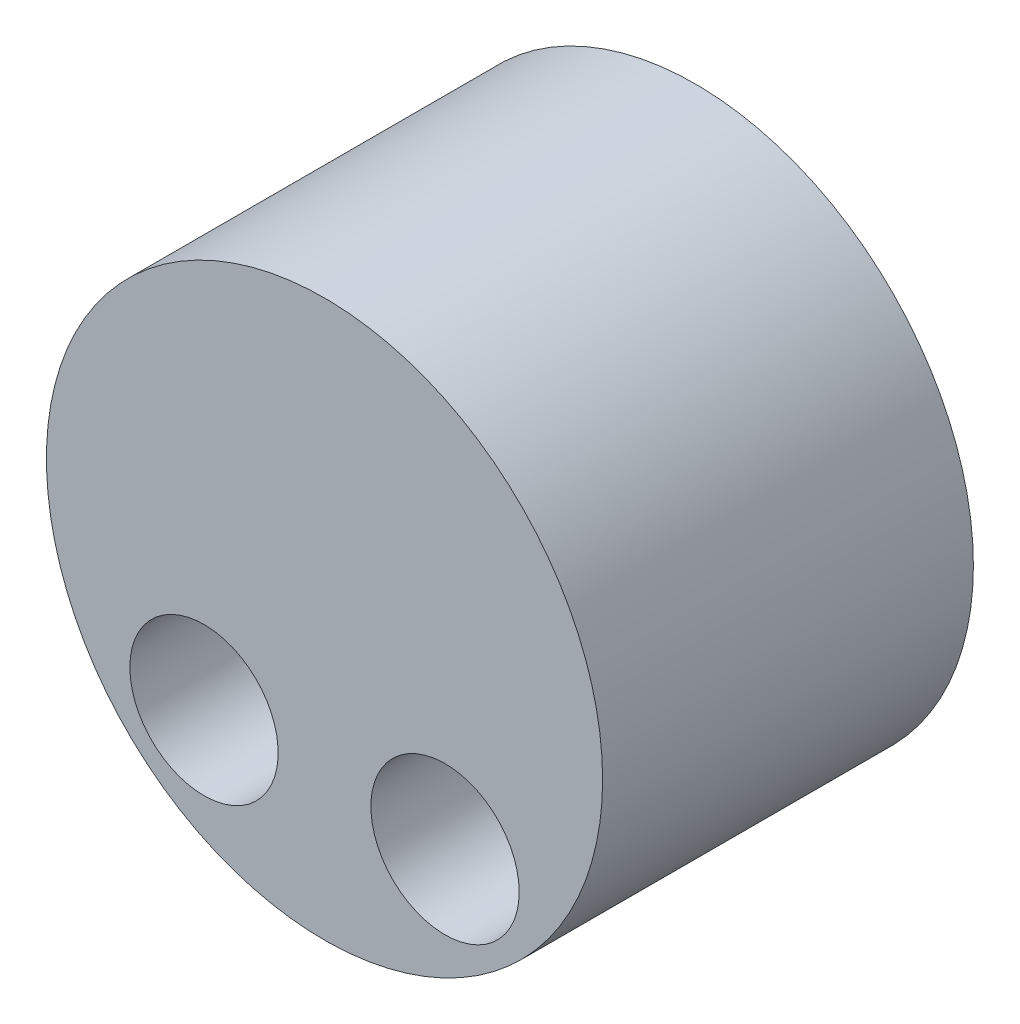
from build123d import *

# Parameters (mm, degrees)
SKETCH_1_R      = 3
SKETCH_1_R_2    = 0.8
EXTRUDE_1_DEPTH = 4


with BuildPart() as part:
    # 草图1 → 凸台-拉伸1 (new body)
    with BuildSketch(Plane.XY):
        Circle(SKETCH_1_R)
        with Locations((1.3, -1.5)):
            Circle(SKETCH_1_R_2, mode=Mode.SUBTRACT)
        with Locations((-1.3, -1.5)):
            Circle(SKETCH_1_R_2, mode=Mode.SUBTRACT)
    extrude(amount=EXTRUDE_1_DEPTH)


solid = part.part
